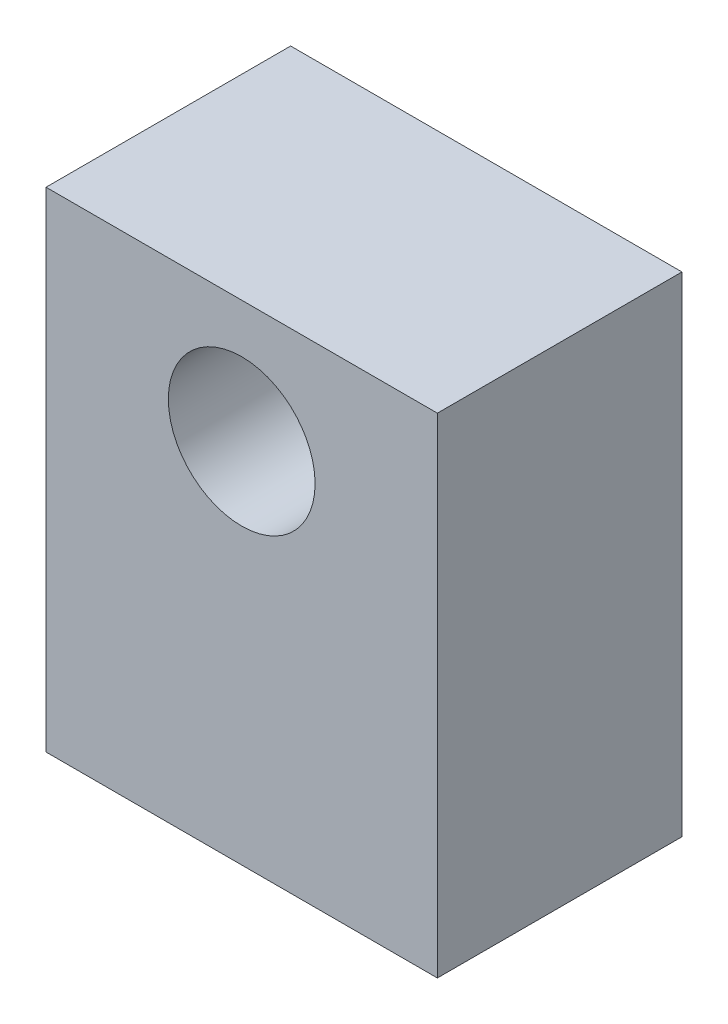
from build123d import *

# Parameters (mm, degrees)
ESQUISSE1_W        = 8
ESQUISSE1_H        = 10
ESQUISSE1_R        = 1.5
BOSS_EXTRU_1_DEPTH = 5


with BuildPart() as part:
    # Esquisse1 → Boss.-Extru.1 (new body)
    with BuildSketch(Plane.XY):
        Rectangle(ESQUISSE1_W, ESQUISSE1_H)
        with Locations((0, 2.5)):
            Circle(ESQUISSE1_R, mode=Mode.SUBTRACT)
    extrude(amount=BOSS_EXTRU_1_DEPTH)


solid = part.part
